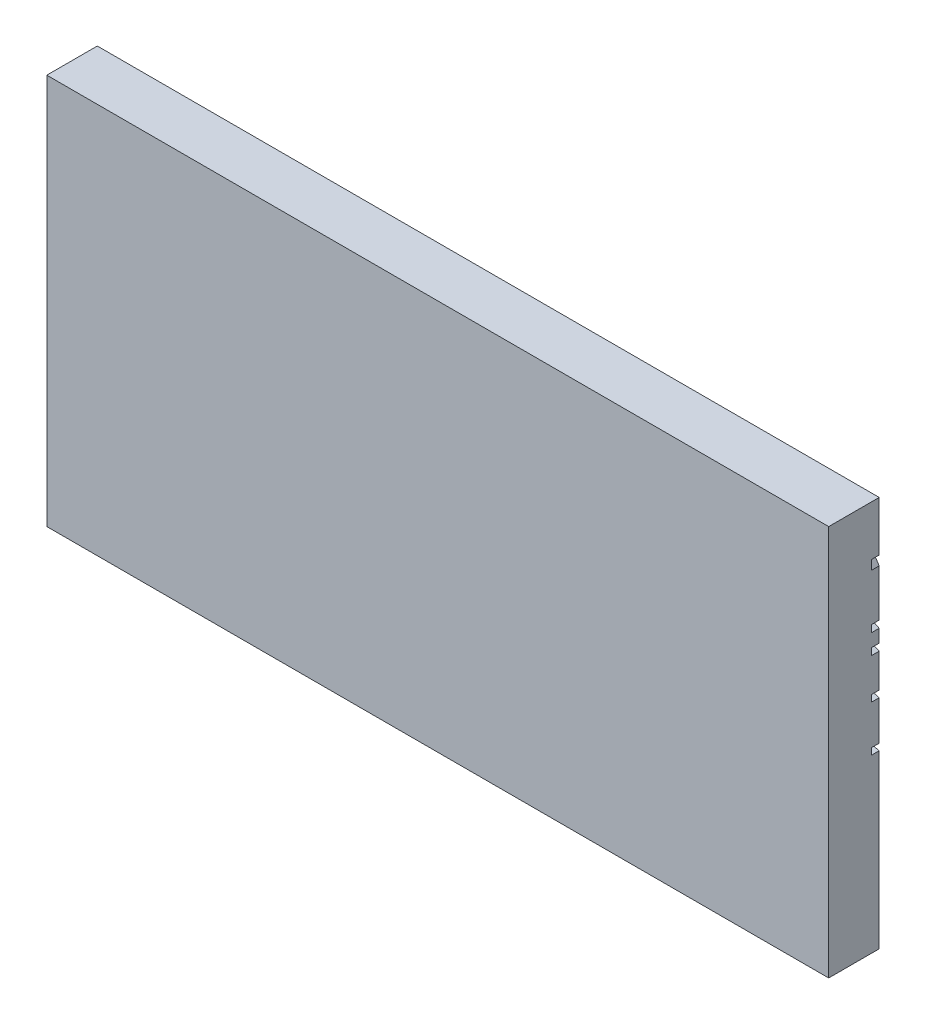
from build123d import *

# Parameters (mm, degrees)
SKETCH1_W           = 152.4
SKETCH1_H           = 76.2
BOSS_EXTRUDE1_DEPTH = 9.8425
CUT_EXTRUDE8_DEPTH  = 1.5


with BuildPart() as part:
    # Sketch1 → Boss-Extrude1 (new body)
    with BuildSketch(Plane.XY):
        with Locations((-23.377517564, 5.621311475)):
            Rectangle(SKETCH1_W, SKETCH1_H)
    extrude(amount=BOSS_EXTRUDE1_DEPTH)

    # Sketch3 → Cut-Extrude8 (cut)
    with BuildSketch(Plane(origin=(0, 0, 0), x_dir=(-1, 0, 0), z_dir=(0, 0, -1))):
        with BuildLine():
            Line((-44.726890699, 19.36528147), (-44.746173598, 20.60513153))
            Line((-44.746173598, 20.60513153), (-48.508169632, 20.546622687))
            add(Edge.make_bspline(
                [(-48.508169632, 20.546622687), (-48.675949577, 20.544013272), (-48.999612816, 20.508916083), (-49.453378931, 20.473147329), (-49.871303207, 20.41073695), (-50.080872244, 20.33969012), (-50.203656688, 20.28530547)],
                knots=[0, 0, 0, 0, 0.294090065, 0.560497026, 0.802762471, 1, 1, 1, 1], degree=3))
            Line((-50.203656688, 20.28530547), (-54.969880773, 18.174212082))
            Line((-54.969880773, 18.174212082), (-54.969880773, 16.818021026))
            Line((-54.969880773, 16.818021026), (-49.701481232, 19.15154191))
            add(Edge.make_bspline(
                [(-49.701481232, 19.15154191), (-49.684189468, 19.159200913), (-49.641908349, 19.176694453), (-49.615145416, 19.185491037), (-49.542253946, 19.205696369), (-49.306018818, 19.23908556), (-49.048707603, 19.261574509), (-48.81409331, 19.283282924), (-48.617674753, 19.301576909), (-48.535974126, 19.306040296), (-48.488886733, 19.306772628)],
                knots=[0, 0, 0, 0, 0.0625, 0.125, 0.25, 0.5, 0.625, 0.75, 0.875, 1, 1, 1, 1], degree=3))
            Line((-48.488886733, 19.306772628), (-44.726890699, 19.36528147))
        make_face()
        with BuildLine():
            Line((-48.51035266, 12.33832191), (-54.640552611, 10.71460266))
            Line((-54.640552611, 10.71460266), (-54.323059589, 9.515937494))
            Line((-54.323059589, 9.515937494), (-48.192859639, 11.139656744))
            add(Edge.make_bspline(
                [(-48.192859639, 11.139656744), (-47.801843994, 11.243225899), (-47.389624666, 11.285533217), (-46.985715874, 11.263681617)],
                knots=[0, 0, 0, 0, 1, 1, 1, 1], degree=3))
            Line((-46.985715874, 11.263681617), (-44.793877153, 11.145102413))
            Line((-44.793877153, 11.145102413), (-44.726890699, 12.383291742))
            Line((-44.726890699, 12.383291742), (-46.91872942, 12.501870946))
            add(Edge.make_bspline(
                [(-46.91872942, 12.501870946), (-47.194365308, 12.516782939), (-47.729183274, 12.503182846), (-48.255253092, 12.405890682), (-48.51035266, 12.33832191)],
                knots=[0, 0, 0, 0, 0.511109576, 1, 1, 1, 1], degree=3))
        make_face()
        with BuildLine():
            Line((-43.695780501, 23.057490694), (-43.585687495, 24.292593738))
            Line((-43.585687495, 24.292593738), (-48.610973749, 24.740531156))
            add(Edge.make_bspline(
                [(-49.729956575, 24.482368714), (-49.65941327, 24.515933386), (-49.446393149, 24.611001503), (-49.075607523, 24.730735276), (-48.767132086, 24.754450595), (-48.610973749, 24.740531156)],
                knots=[0, 0, 0, 0, 0.202889278, 0.601788175, 1, 1, 1, 1], degree=3))
            Line((-49.729956575, 24.482368714), (-54.87453465, 22.034566258))
            Line((-54.87453465, 22.034566258), (-54.87453465, 20.661360507))
            Line((-54.87453465, 20.661360507), (-49.197193201, 23.362653042))
            add(Edge.make_bspline(
                [(-49.197193201, 23.362653042), (-49.139010306, 23.390336601), (-49.01099741, 23.446228058), (-48.872225099, 23.490335328), (-48.768651785, 23.507240994), (-48.740242067, 23.507137336), (-48.721066755, 23.505428112)],
                knots=[0, 0, 0, 0, 0.25, 0.5, 0.75, 1, 1, 1, 1], degree=3))
            Line((-48.721066755, 23.505428112), (-43.695780501, 23.057490694))
        make_face()
        with BuildLine():
            Line((-50.927422497, 36.90011515), (-54.94436907, 30.743988904))
            Line((-54.94436907, 30.743988904), (-54.94436907, 28.914050382))
            Line((-54.94436907, 28.914050382), (-50.061346642, 36.39747143))
            add(Edge.make_bspline(
                [(-49.576742638, 36.923837605), (-49.646063205, 36.847240879), (-49.809278874, 36.686241544), (-49.959721756, 36.541529579), (-50.019559683, 36.473902058), (-50.039690523, 36.439546623), (-50.030564548, 36.457569967), (-50.053366622, 36.413042841), (-50.061346642, 36.39747143)],
                knots=[0, 0, 0, 0, 0.26390369, 0.527807381, 0.791711071, 0.923662916, 0.989638839, 1.055614761, 1.055614761, 1.055614761, 1.055614761], degree=3))
            Line((-49.576742638, 36.923837605), (-48.093832254, 38.562400084))
            Line((-48.093832254, 38.562400084), (-48.835277647, 39.233413296))
            Line((-48.835277647, 39.233413296), (-50.31818803, 37.594850816))
            add(Edge.make_bspline(
                [(-50.31818803, 37.594850816), (-50.385599817, 37.520363224), (-50.609375158, 37.305637276), (-50.831157934, 37.08795617), (-50.927422497, 36.90011515)],
                knots=[0, 0, 0, 0, 0.326998241, 1, 1, 1, 1], degree=3))
        make_face()
        with BuildLine():
            Line((-46.996369813, 3.618538944), (-54.86449918, 1.747502797))
            Line((-54.86449918, 1.747502797), (-54.577627521, 0.541142713))
            Line((-54.577627521, 0.541142713), (-46.709498155, 2.41217886))
            add(Edge.make_bspline(
                [(-46.709498155, 2.41217886), (-46.535591864, 2.453533665), (-46.354408424, 2.471188006), (-46.17578104, 2.46441487)],
                knots=[0, 0, 0, 0, 1, 1, 1, 1], degree=3))
            Line((-46.17578104, 2.46441487), (-43.632671657, 2.367986057))
            Line((-43.632671657, 2.367986057), (-43.585687495, 3.607095611))
            Line((-43.585687495, 3.607095611), (-46.128796878, 3.703524424))
            add(Edge.make_bspline(
                [(-46.128796878, 3.703524424), (-46.291398125, 3.709689887), (-46.582443275, 3.698945442), (-46.869328394, 3.648749312), (-46.996369813, 3.618538944)],
                knots=[0, 0, 0, 0, 0.554289031, 1, 1, 1, 1], degree=3))
        make_face()
    extrude(amount=-CUT_EXTRUDE8_DEPTH, mode=Mode.SUBTRACT)


solid = part.part
